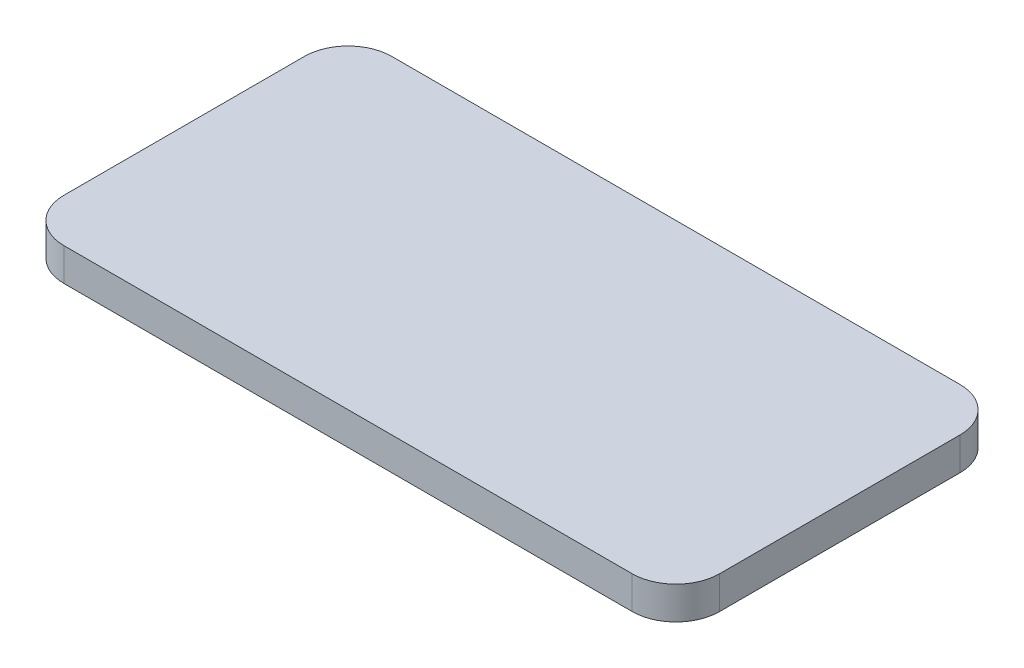
from build123d import *

# Parameters (mm, degrees)
EXTRUDE_1_DEPTH = 1.5


with BuildPart() as part:
    # 草图1 → 凸台-拉伸1 (new body)
    with BuildSketch(Plane(origin=(0, 0, 0), x_dir=(1, 0, 0), z_dir=(0, 1, 0))):
        with BuildLine():
            Line((-13, -7.5), (13, -7.5))
            ThreePointArc((13, -7.5), (14.414213562, -6.914213562), (15, -5.5))
            Line((15, -5.5), (15, 5.5))
            ThreePointArc((15, 5.5), (14.414213562, 6.914213562), (13, 7.5))
            Line((13, 7.5), (-13, 7.5))
            ThreePointArc((-13, 7.5), (-14.414213562, 6.914213562), (-15, 5.5))
            Line((-15, 5.5), (-15, -5.5))
            ThreePointArc((-15, -5.5), (-14.414213562, -6.914213562), (-13, -7.5))
        make_face()
    extrude(amount=EXTRUDE_1_DEPTH)


solid = part.part
